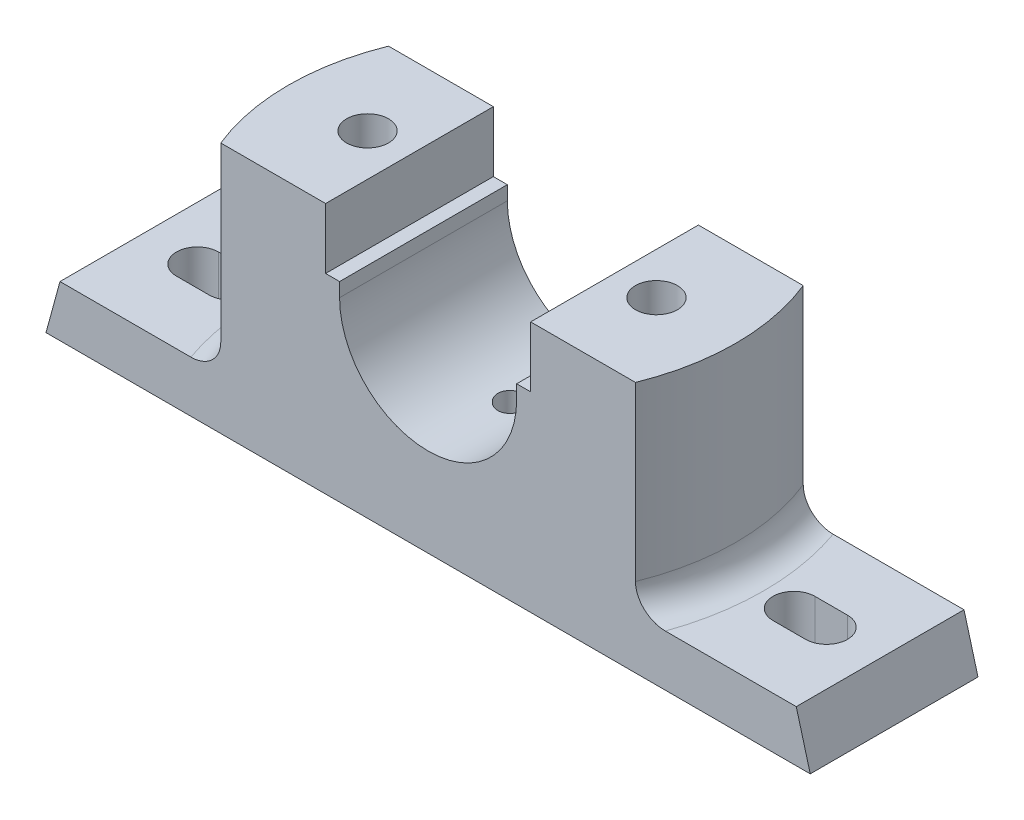
from build123d import *

# Parameters (mm, degrees)
BOSS_EXTRUDE1_DEPTH          = 18
CUT_EXTRUDE1_DEPTH           = 43
FILLET2_R                    = 6
F_6_0_6_DIAMETER_HOLE1_D     = 6
F_6_0_6_DIAMETER_HOLE1_DEPTH = 6
F_6_0_6_DIAMETER_HOLE1_TIP   = 1.802581857
CUT_EXTRUDE2_DEPTH           = 12.0000001
F_6_0_6_DIAMETER_HOLE2_D     = 9
SKETCH24_W                   = 20
SKETCH24_H                   = 20
CUT_EXTRUDE3_DEPTH           = 8


with BuildPart() as part:
    # Sketch1 → Boss-Extrude1 (new body, symmetric)
    with BuildSketch(Plane.XY):
        with BuildLine():
            Line((-82, 0), (82, 0))
            Line((82, 0), (79, 11))
            Line((79, 11), (50, 11))
            Line((50, 11), (50, 54))
            Line((50, 54), (22, 54))
            Line((22, 54), (22, 41))
            Line((22, 41), (19, 41))
            Line((19, 41), (19, 38))
            ThreePointArc((19, 38), (13.435028843, 24.564971157), (0, 19))
            ThreePointArc((0, 19), (-13.435028843, 24.564971157), (-19, 38))
            Line((-19, 38), (-19, 41))
            Line((-19, 41), (-22, 41))
            Line((-22, 41), (-22, 54))
            Line((-22, 54), (-50, 54))
            Line((-50, 54), (-50, 11))
            Line((-50, 11), (-79, 11))
            Line((-79, 11), (-82, 0))
        make_face()
    extrude(amount=BOSS_EXTRUDE1_DEPTH, both=True)

    # Sketch5 → Cut-Extrude1 (cut)
    with BuildSketch(Plane(origin=(0, 54, 0), x_dir=(1, 0, 0), z_dir=(0, 1, 0))):
        with BuildLine():
            Line((-44.497190923, 18), (-50, 18))
            Line((-50, 18), (-50, -18))
            Line((-50, -18), (-44.497190923, -18))
            ThreePointArc((-44.497190923, -18), (-48, 0), (-44.497190923, 18))
        make_face()
        with BuildLine():
            Line((50, -18), (44.497190923, -18))
            ThreePointArc((44.497190923, -18), (48, 0), (44.497190923, 18))
            Line((44.497190923, 18), (50, 18))
            Line((50, 18), (50, -18))
        make_face()
    extrude(amount=-CUT_EXTRUDE1_DEPTH, mode=Mode.SUBTRACT)

    # Fillet2
    fillet2_edges = [part.edges().sort_by_distance(p)[0] for p in [
        (-48, 11, 0),
        (48, 11, 0),
    ]]
    fillet(fillet2_edges, radius=FILLET2_R)

    # Ø6.0 (6) Diameter Hole1
    with Locations(Plane(origin=(0, 19, 0), x_dir=(1, 0, 0), z_dir=(0, 1, 0))):
        with Locations((0, 0)):
            Hole(F_6_0_6_DIAMETER_HOLE1_D / 2, depth=F_6_0_6_DIAMETER_HOLE1_DEPTH)
            with Locations((0, 0, -(F_6_0_6_DIAMETER_HOLE1_DEPTH + F_6_0_6_DIAMETER_HOLE1_TIP / 2))):  # 118° drill point
                Cone(0, F_6_0_6_DIAMETER_HOLE1_D / 2, F_6_0_6_DIAMETER_HOLE1_TIP, mode=Mode.SUBTRACT)

    # Sketch20 → Cut-Extrude2 (cut, through all)
    with BuildSketch(Plane(origin=(0, 11, 0), x_dir=(1, 0, 0), z_dir=(0, 1, 0))):
        with BuildLine():
            Line((-67.5, 4.5), (-60.5, 4.5))
            ThreePointArc((-60.5, 4.5), (-56, 0), (-60.5, -4.5))
            Line((-60.5, -4.5), (-67.5, -4.5))
            ThreePointArc((-67.5, -4.5), (-72, 0), (-67.5, 4.5))
        make_face()
    cut_extrude2 = extrude(amount=-CUT_EXTRUDE2_DEPTH, mode=Mode.SUBTRACT)

    # Ø6.0 (6) Diameter Hole2 (through all)
    with Locations(Plane(origin=(0, 54, 0), x_dir=(1, 0, 0), z_dir=(0, 1, 0))):
        with Locations((-31, 0)):
            f_6_0_6_diameter_hole2 = Hole(F_6_0_6_DIAMETER_HOLE2_D / 2)

    # Sketch24 → Cut-Extrude3 (cut)
    with BuildSketch(Plane.XZ):
        with Locations((-31, 0)):
            Rectangle(SKETCH24_W, SKETCH24_H)
    cut_extrude3 = extrude(amount=-CUT_EXTRUDE3_DEPTH, mode=Mode.SUBTRACT)

    # Mirror1: Cut-Extrude2, Ø6.0 (6) Diameter Hole2, Cut-Extrude3 across plane
    add(cut_extrude2.mirror(Plane(origin=(0, 0, 0), x_dir=(0, 0, 1), z_dir=(1, 0, 0))), mode=Mode.SUBTRACT)
    add(f_6_0_6_diameter_hole2.mirror(Plane(origin=(0, 0, 0), x_dir=(0, 0, 1), z_dir=(1, 0, 0))), mode=Mode.SUBTRACT)
    add(cut_extrude3.mirror(Plane(origin=(0, 0, 0), x_dir=(0, 0, 1), z_dir=(1, 0, 0))), mode=Mode.SUBTRACT)


solid = part.part
